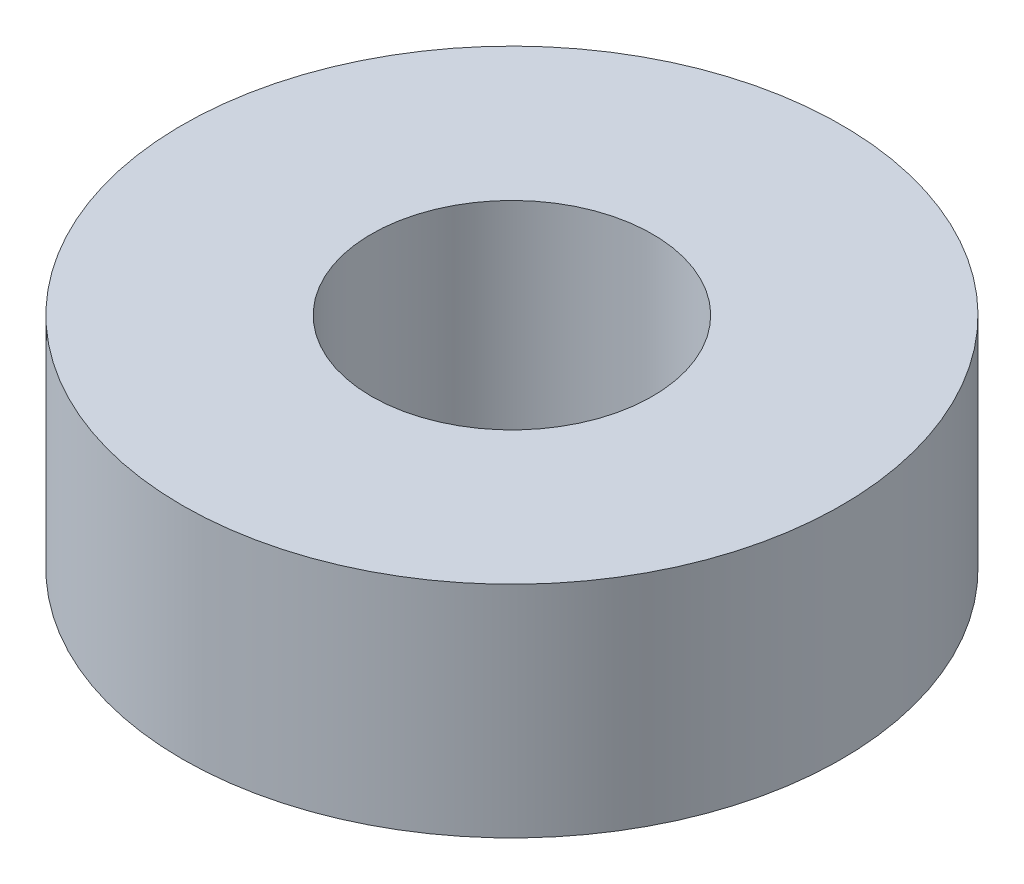
from build123d import *

# Parameters (mm, degrees)
SKETCH1_R           = 15.24
SKETCH1_R_2         = 6.5
BOSS_EXTRUDE1_DEPTH = 10.16


with BuildPart() as part:
    # Sketch1 → Boss-Extrude1 (new body)
    with BuildSketch(Plane(origin=(0, 0, 0), x_dir=(1, 0, 0), z_dir=(0, 1, 0))):
        Circle(SKETCH1_R)
        Circle(SKETCH1_R_2, mode=Mode.SUBTRACT)
    extrude(amount=BOSS_EXTRUDE1_DEPTH)


solid = part.part
